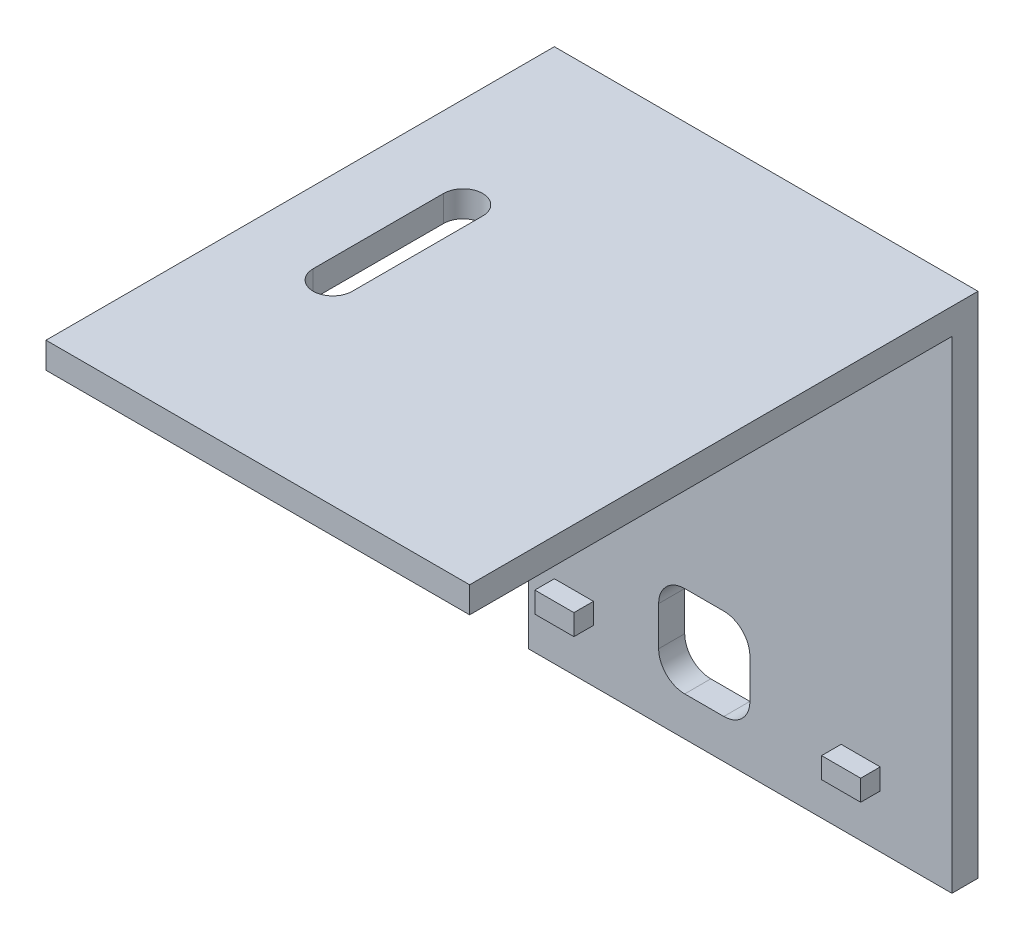
from build123d import *

# Parameters (mm, degrees)
SKETCH1_W           = 32.5
SKETCH1_H           = 37
BOSS_EXTRUDE1_DEPTH = 2
SKETCH2_W           = 3
SKETCH2_H           = 1.6
BOSS_EXTRUDE2_DEPTH = 1.5
SKETCH3_W           = 7
SKETCH3_H           = 7
CUT_EXTRUDE1_DEPTH  = 4.5
FILLET1_R           = 2
SKETCH4_W           = 32.5
SKETCH4_H           = 39
BOSS_EXTRUDE3_DEPTH = 2
CUT_EXTRUDE2_DEPTH  = 2


with BuildPart() as part:
    # Sketch1 → Boss-Extrude1 (new body)
    with BuildSketch(Plane.XY):
        Rectangle(SKETCH1_W, SKETCH1_H)
    extrude(amount=BOSS_EXTRUDE1_DEPTH)

    # Sketch2 → Boss-Extrude2 (add)
    with BuildSketch(Plane.XY.offset(2)):
        with Locations((-12.75, -13.65)):
            Rectangle(SKETCH2_W, SKETCH2_H)
        with Locations((9.25, -13.65)):
            Rectangle(SKETCH2_W, SKETCH2_H)
    extrude(amount=BOSS_EXTRUDE2_DEPTH)

    # Sketch3 → Cut-Extrude1 (cut, through all)
    with BuildSketch(Plane(origin=(0, 0, 0), x_dir=(-1, 0, 0), z_dir=(0, 0, -1))):
        with Locations((2.75, -12)):
            Rectangle(SKETCH3_W, SKETCH3_H)
    extrude(amount=-CUT_EXTRUDE1_DEPTH, mode=Mode.SUBTRACT)

    # Fillet1
    fillet1_edges = [part.edges().sort_by_distance(p)[0] for p in [
        (0.75, -15.5, 1),
        (0.75, -8.5, 1),
        (-6.25, -8.5, 1),
        (-6.25, -15.5, 1),
    ]]
    fillet(fillet1_edges, radius=FILLET1_R)

    # Sketch4 → Boss-Extrude3 (add)
    with BuildSketch(Plane(origin=(0, 18.5, 0), x_dir=(1, 0, 0), z_dir=(0, 1, 0))):
        with Locations((0, -19.5)):
            Rectangle(SKETCH4_W, SKETCH4_H)
    extrude(amount=BOSS_EXTRUDE3_DEPTH)

    # Sketch5 → Cut-Extrude2 (cut)
    with BuildSketch(Plane(origin=(0, 20.5, 0), x_dir=(1, 0, 0), z_dir=(0, 1, 0))):
        with BuildLine():
            Line((-10.75, -24), (-10.75, -14))
            ThreePointArc((-10.75, -14), (-9.25, -12.5), (-7.75, -14))
            Line((-7.75, -14), (-7.75, -24))
            ThreePointArc((-7.75, -24), (-9.25, -25.5), (-10.75, -24))
        make_face()
    extrude(amount=-CUT_EXTRUDE2_DEPTH, mode=Mode.SUBTRACT)


solid = part.part
